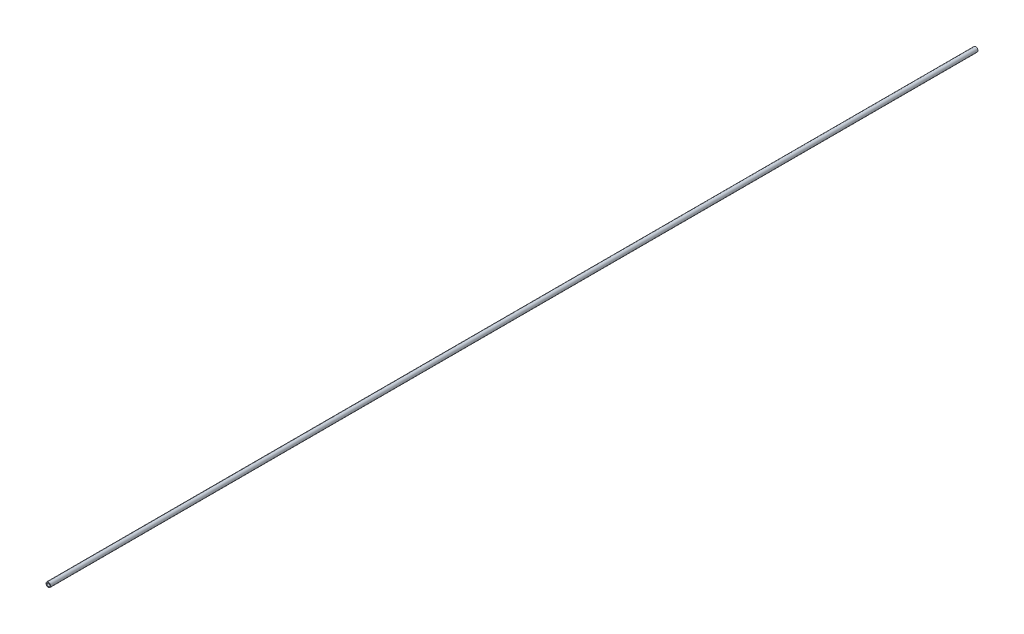
from build123d import *

# Parameters (mm, degrees)
SKETCH1_R           = 2.5
SKETCH1_R_2         = 1.6
BOSS_EXTRUDE1_DEPTH = 1000


with BuildPart() as part:
    # Sketch1 → Boss-Extrude1 (new body)
    with BuildSketch(Plane.XY):
        Circle(SKETCH1_R)
        Circle(SKETCH1_R_2, mode=Mode.SUBTRACT)
    extrude(amount=BOSS_EXTRUDE1_DEPTH)


solid = part.part
